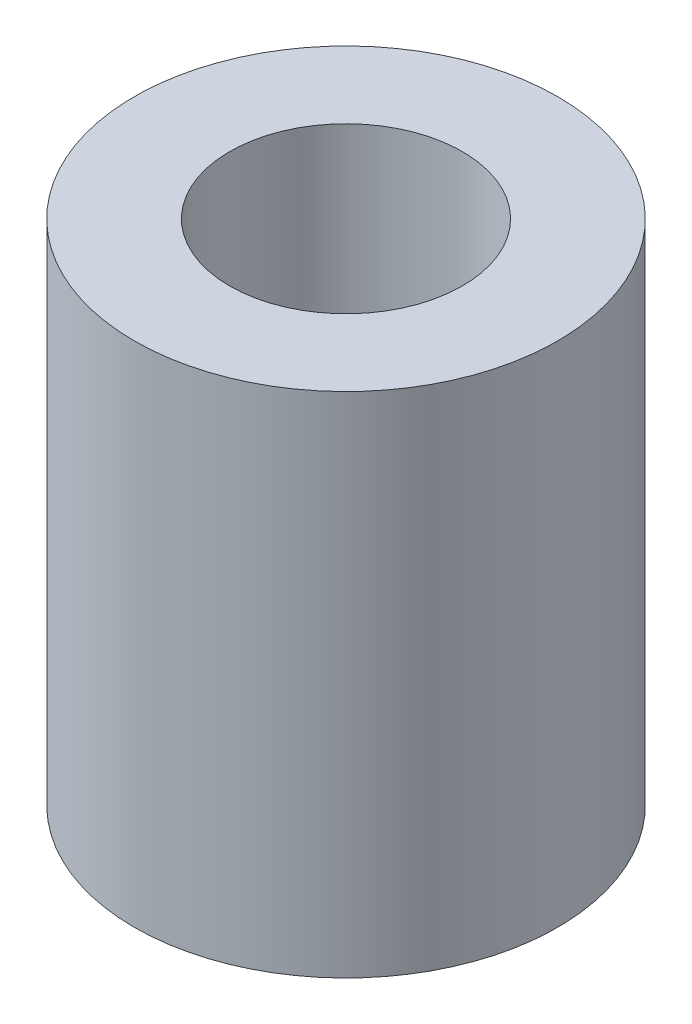
from build123d import *

# Parameters (mm, degrees)
ESQUISSE1_R             = 5
EXTRUSION1_DEPTH        = 12
ESQUISSE2_R             = 2.75
ENL_V_MAT_EXTRU_1_DEPTH = 13


with BuildPart() as part:
    # Esquisse1 → Extrusion1 (new body)
    with BuildSketch(Plane(origin=(0, 0, 0), x_dir=(1, 0, 0), z_dir=(0, 1, 0))):
        Circle(ESQUISSE1_R)
    extrude(amount=EXTRUSION1_DEPTH)

    # Esquisse2 → Enlèv. mat.-Extru.1 (cut, through all)
    with BuildSketch(Plane(origin=(0, 12, 0), x_dir=(1, 0, 0), z_dir=(0, 1, 0))):
        Circle(ESQUISSE2_R)
    extrude(amount=-ENL_V_MAT_EXTRU_1_DEPTH, mode=Mode.SUBTRACT)


solid = part.part
